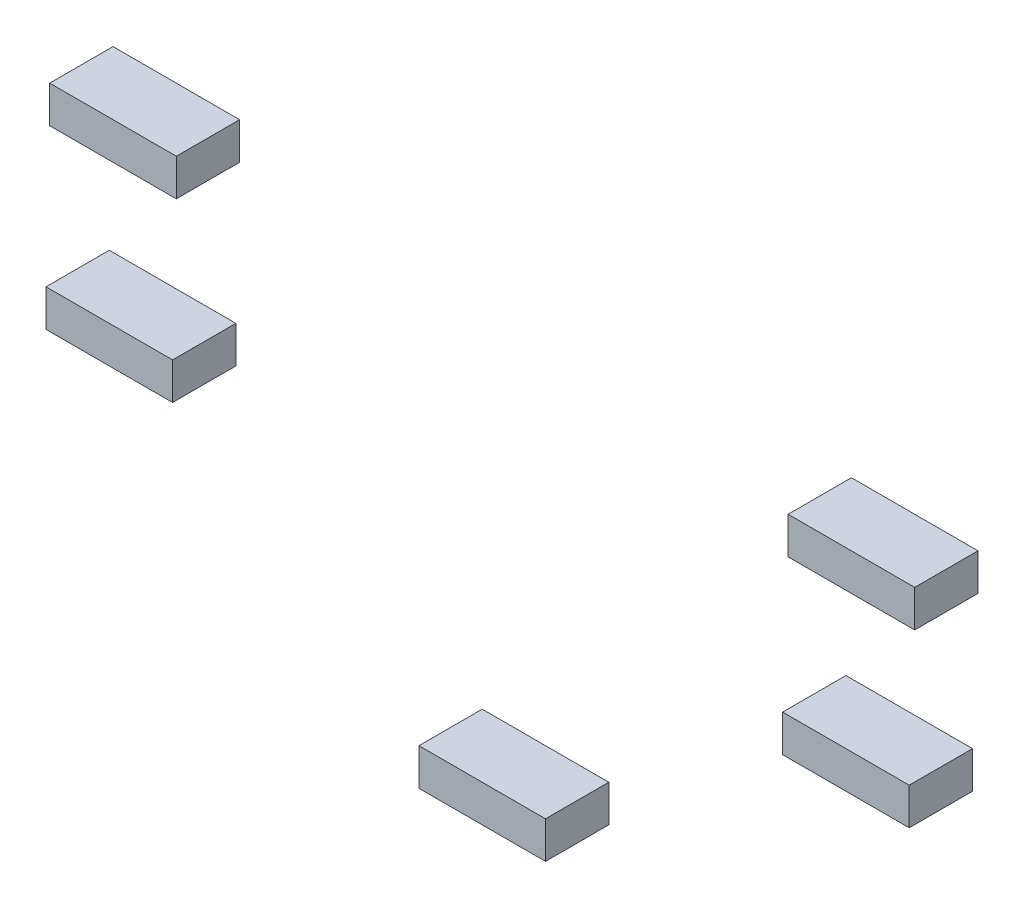
from build123d import *

# Parameters (mm, degrees)
SKETCH1_W        = 1200
SKETCH1_H        = 350
EXTRUDE1_DEPTH   = 600
EXTRUDE1_2_DEPTH = 600
EXTRUDE1_3_DEPTH = 600
EXTRUDE1_4_DEPTH = 600
EXTRUDE1_5_DEPTH = 600


with BuildPart() as part:
    # Sketch1 → Extrude1 (new body)
    with BuildSketch(Plane.XY):
        with Locations((66937.057737679, 23591.633625626)):
            Rectangle(SKETCH1_W, SKETCH1_H)
    extrude(amount=EXTRUDE1_DEPTH)


with BuildPart() as body_2:
    # Sketch1 → Extrude1 2 (new body)
    with BuildSketch(Plane.XY):
        with Locations((70385.142636984, 25591.633625626)):
            Rectangle(SKETCH1_W, SKETCH1_H)
    extrude(amount=EXTRUDE1_2_DEPTH)


with BuildPart() as body_3:
    # Sketch1 → Extrude1 3 (new body)
    with BuildSketch(Plane.XY):
        with Locations((70437.057737679, 27241.633625626)):
            Rectangle(SKETCH1_W, SKETCH1_H)
    extrude(amount=EXTRUDE1_3_DEPTH)


with BuildPart() as body_4:
    # Sketch1 → Extrude1 4 (new body)
    with BuildSketch(Plane.XY):
        with Locations((63437.057737679, 27281.170364801)):
            Rectangle(SKETCH1_W, SKETCH1_H)
    extrude(amount=EXTRUDE1_4_DEPTH)


with BuildPart() as body_5:
    # Sketch1 → Extrude1 5 (new body)
    with BuildSketch(Plane.XY):
        with Locations((63401.819180271, 25591.443706088)):
            Rectangle(SKETCH1_W, SKETCH1_H)
    extrude(amount=EXTRUDE1_5_DEPTH)


solid = Compound([part.part, body_2.part, body_3.part, body_4.part, body_5.part])
